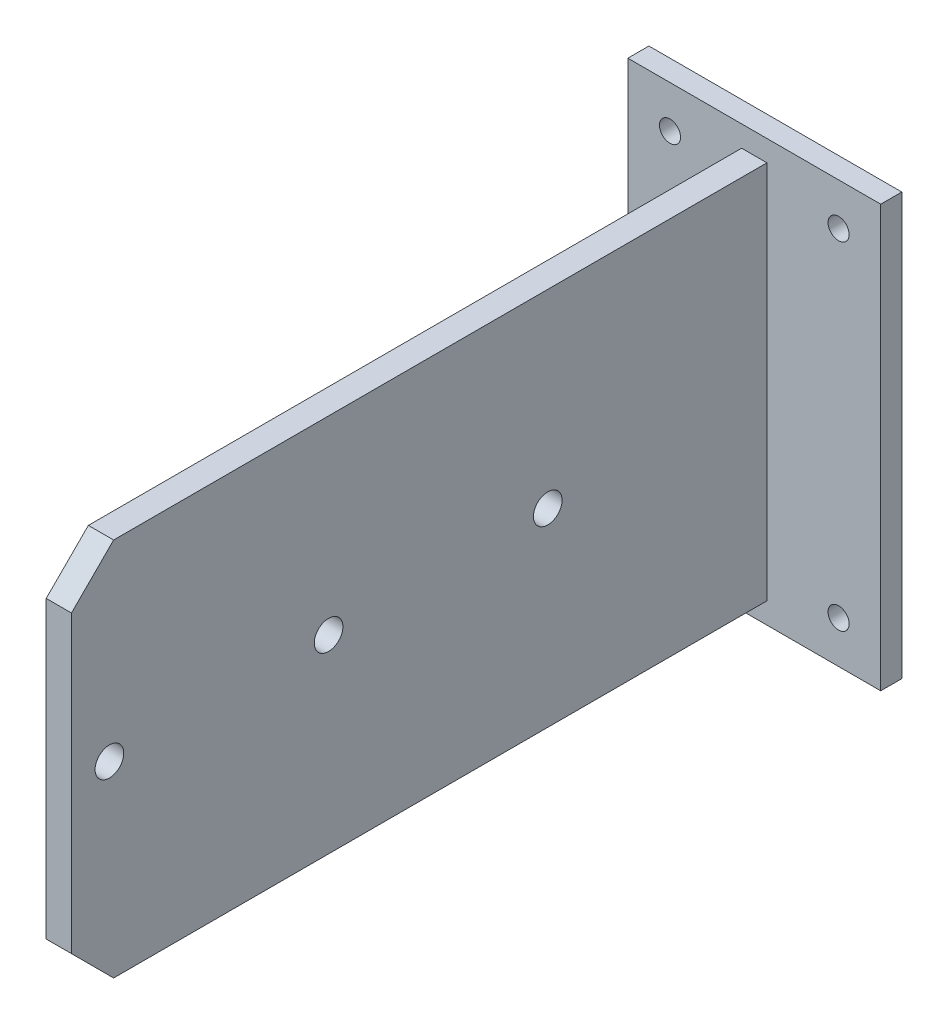
from build123d import *

# Parameters (mm, degrees)
SKETCH1_W           = 60
SKETCH1_H           = 100
SKETCH1_R           = 2.5
BOSS_EXTRUDE1_DEPTH = 5
SKETCH2_W           = 6
SKETCH2_H           = 90
BOSS_EXTRUDE2_DEPTH = 165
CHAMFER1_SIZE       = 10
SKETCH3_R           = 3.4
CUT_EXTRUDE1_DEPTH  = 165


with BuildPart() as part:
    # Sketch1 → Boss-Extrude1 (new body)
    with BuildSketch(Plane.XY):
        Rectangle(SKETCH1_W, SKETCH1_H)
        with Locations((-20, 40)):
            Circle(SKETCH1_R, mode=Mode.SUBTRACT)
        with Locations((20, 40)):
            Circle(SKETCH1_R, mode=Mode.SUBTRACT)
        with Locations((20, -40)):
            Circle(SKETCH1_R, mode=Mode.SUBTRACT)
        with Locations((-20, -40)):
            Circle(SKETCH1_R, mode=Mode.SUBTRACT)
    extrude(amount=BOSS_EXTRUDE1_DEPTH)

    # Sketch2 → Boss-Extrude2 (add)
    with BuildSketch(Plane.XY.offset(5)):
        Rectangle(SKETCH2_W, SKETCH2_H)
    extrude(amount=BOSS_EXTRUDE2_DEPTH)

    # Chamfer1
    chamfer1_edges = [part.edges().sort_by_distance(p)[0] for p in [
        (0, 45, 170),
        (0, -45, 170),
    ]]
    chamfer(chamfer1_edges, length=CHAMFER1_SIZE)

    # Sketch3 → Cut-Extrude1 (cut)
    with BuildSketch(Plane.ZY.offset(3)):
        with Locations((161, 0)):
            Circle(SKETCH3_R)
        with Locations((109, 0)):
            Circle(SKETCH3_R)
        with Locations((57, 0)):
            Circle(SKETCH3_R)
    extrude(amount=-CUT_EXTRUDE1_DEPTH, mode=Mode.SUBTRACT)


solid = part.part
